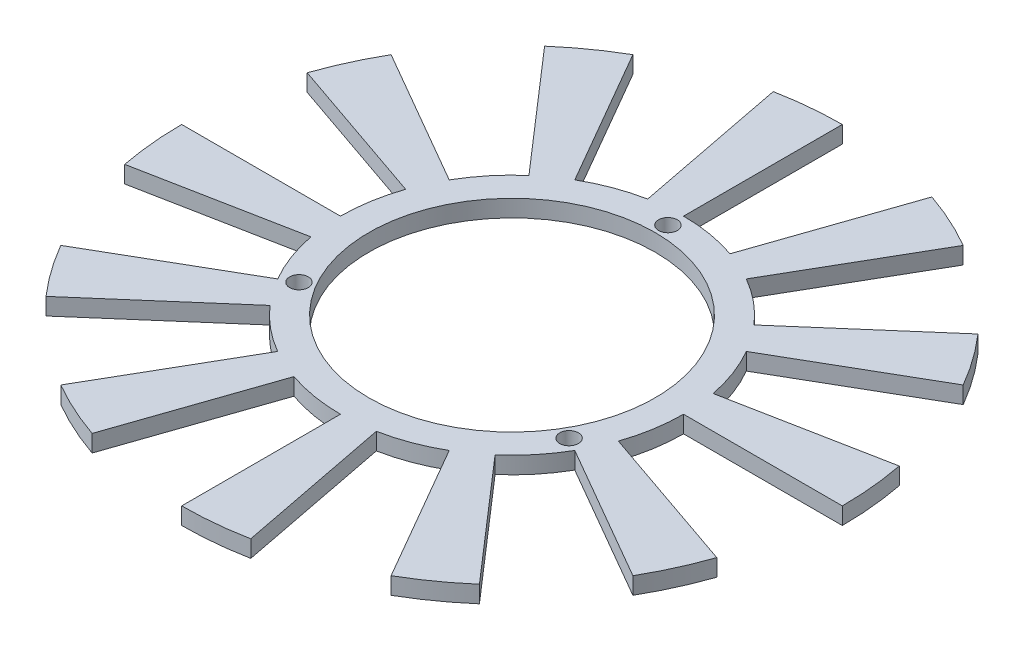
from build123d import *

# Parameters (mm, degrees)
SKETCH1_R           = 30.25
SKETCH1_R_2         = 25.25
EXTRUDE_THIN1_DEPTH = 3
SKETCH2_R           = 1.65
CUT_EXTRUDE3_DEPTH  = 10
BOSS_EXTRUDE1_DEPTH = 3


with BuildPart() as part:
    # Sketch1 → Extrude-Thin1 (new body)
    with BuildSketch(Plane(origin=(0, 0, 0), x_dir=(1, 0, 0), z_dir=(0, 1, 0))):
        Circle(SKETCH1_R)
        Circle(SKETCH1_R_2, mode=Mode.SUBTRACT)
    extrude(amount=-EXTRUDE_THIN1_DEPTH)

    # Sketch2 → Cut-Extrude3 (cut)
    with BuildSketch(Plane(origin=(0, 0, 0), x_dir=(1, 0, 0), z_dir=(0, 1, 0))):
        with Locations((0, 27.5)):
            Circle(SKETCH2_R)
        with Locations((23.815698604, -13.75)):
            Circle(SKETCH2_R)
        with Locations((-23.815698604, -13.75)):
            Circle(SKETCH2_R)
    extrude(amount=-CUT_EXTRUDE3_DEPTH, mode=Mode.SUBTRACT)

    # Sketch5 → Boss-Extrude1 (add)
    with BuildSketch(Plane.XZ.offset(3)):
        with BuildLine():
            Line((0, 58.25), (0, 30.25))
            ThreePointArc((0, 30.25), (2.899334014, 30.110735001), (5.77197211, 29.694222299))
            Line((5.77197211, 29.694222299), (11.114623981, 57.179783436))
            ThreePointArc((11.114623981, 57.179783436), (5.583015084, 57.981828555), (0, 58.25))
        make_face()
        with BuildLine():
            Line((29.125, 50.44597977), (15.125, 26.197268464))
            ThreePointArc((15.125, 26.197268464), (17.56626441, 24.62699443), (19.845785627, 22.829964802))
            Line((19.845785627, 22.829964802), (38.215438439, 43.961833048))
            ThreePointArc((38.215438439, 43.961833048), (33.82594717, 47.422228944), (29.125, 50.44597977))
        make_face()
        with BuildLine():
            Line((50.44597977, 29.125), (26.197268464, 15.125))
            ThreePointArc((26.197268464, 15.125), (27.526328444, 12.54447059), (28.601936912, 9.848436672))
            Line((28.601936912, 9.848436672), (55.076457029, 18.964344997))
            ThreePointArc((55.076457029, 18.964344997), (53.005244029, 24.155881385), (50.44597977, 29.125))
        make_face()
        with BuildLine():
            Line((58.25, 0), (30.25, 0))
            ThreePointArc((30.25, 0), (30.110735001, -2.899334014), (29.694222299, -5.77197211))
            Line((29.694222299, -5.77197211), (57.179783436, -11.114623981))
            ThreePointArc((57.179783436, -11.114623981), (57.981828555, -5.583015084), (58.25, 0))
        make_face()
        with BuildLine():
            Line((50.44597977, -29.125), (26.197268464, -15.125))
            ThreePointArc((26.197268464, -15.125), (24.62699443, -17.56626441), (22.829964802, -19.845785627))
            Line((22.829964802, -19.845785627), (43.961833048, -38.215438439))
            ThreePointArc((43.961833048, -38.215438439), (47.422228944, -33.82594717), (50.44597977, -29.125))
        make_face()
        with BuildLine():
            Line((29.125, -50.44597977), (15.125, -26.197268464))
            ThreePointArc((15.125, -26.197268464), (12.54447059, -27.526328444), (9.848436672, -28.601936912))
            Line((9.848436672, -28.601936912), (18.964344997, -55.076457029))
            ThreePointArc((18.964344997, -55.076457029), (24.155881385, -53.005244029), (29.125, -50.44597977))
        make_face()
        with BuildLine():
            Line((0, -58.25), (0, -30.25))
            ThreePointArc((0, -30.25), (-2.899334014, -30.110735001), (-5.77197211, -29.694222299))
            Line((-5.77197211, -29.694222299), (-11.114623981, -57.179783436))
            ThreePointArc((-11.114623981, -57.179783436), (-5.583015084, -57.981828555), (0, -58.25))
        make_face()
        with BuildLine():
            Line((-29.125, -50.44597977), (-15.125, -26.197268464))
            ThreePointArc((-15.125, -26.197268464), (-17.56626441, -24.62699443), (-19.845785627, -22.829964802))
            Line((-19.845785627, -22.829964802), (-38.215438439, -43.961833048))
            ThreePointArc((-38.215438439, -43.961833048), (-33.82594717, -47.422228944), (-29.125, -50.44597977))
        make_face()
        with BuildLine():
            Line((-50.44597977, -29.125), (-26.197268464, -15.125))
            ThreePointArc((-26.197268464, -15.125), (-27.526328444, -12.54447059), (-28.601936912, -9.848436672))
            Line((-28.601936912, -9.848436672), (-55.076457029, -18.964344997))
            ThreePointArc((-55.076457029, -18.964344997), (-53.005244029, -24.155881385), (-50.44597977, -29.125))
        make_face()
        with BuildLine():
            Line((-58.25, 0), (-30.25, 0))
            ThreePointArc((-30.25, 0), (-30.110735001, 2.899334014), (-29.694222299, 5.77197211))
            Line((-29.694222299, 5.77197211), (-57.179783436, 11.114623981))
            ThreePointArc((-57.179783436, 11.114623981), (-57.981828555, 5.583015084), (-58.25, 0))
        make_face()
        with BuildLine():
            Line((-50.44597977, 29.125), (-26.197268464, 15.125))
            ThreePointArc((-26.197268464, 15.125), (-24.62699443, 17.56626441), (-22.829964802, 19.845785627))
            Line((-22.829964802, 19.845785627), (-43.961833048, 38.215438439))
            ThreePointArc((-43.961833048, 38.215438439), (-47.422228944, 33.82594717), (-50.44597977, 29.125))
        make_face()
        with BuildLine():
            Line((-29.125, 50.44597977), (-15.125, 26.197268464))
            ThreePointArc((-15.125, 26.197268464), (-12.54447059, 27.526328444), (-9.848436672, 28.601936912))
            Line((-9.848436672, 28.601936912), (-18.964344997, 55.076457029))
            ThreePointArc((-18.964344997, 55.076457029), (-24.155881385, 53.005244029), (-29.125, 50.44597977))
        make_face()
    extrude(amount=-BOSS_EXTRUDE1_DEPTH)


solid = part.part
